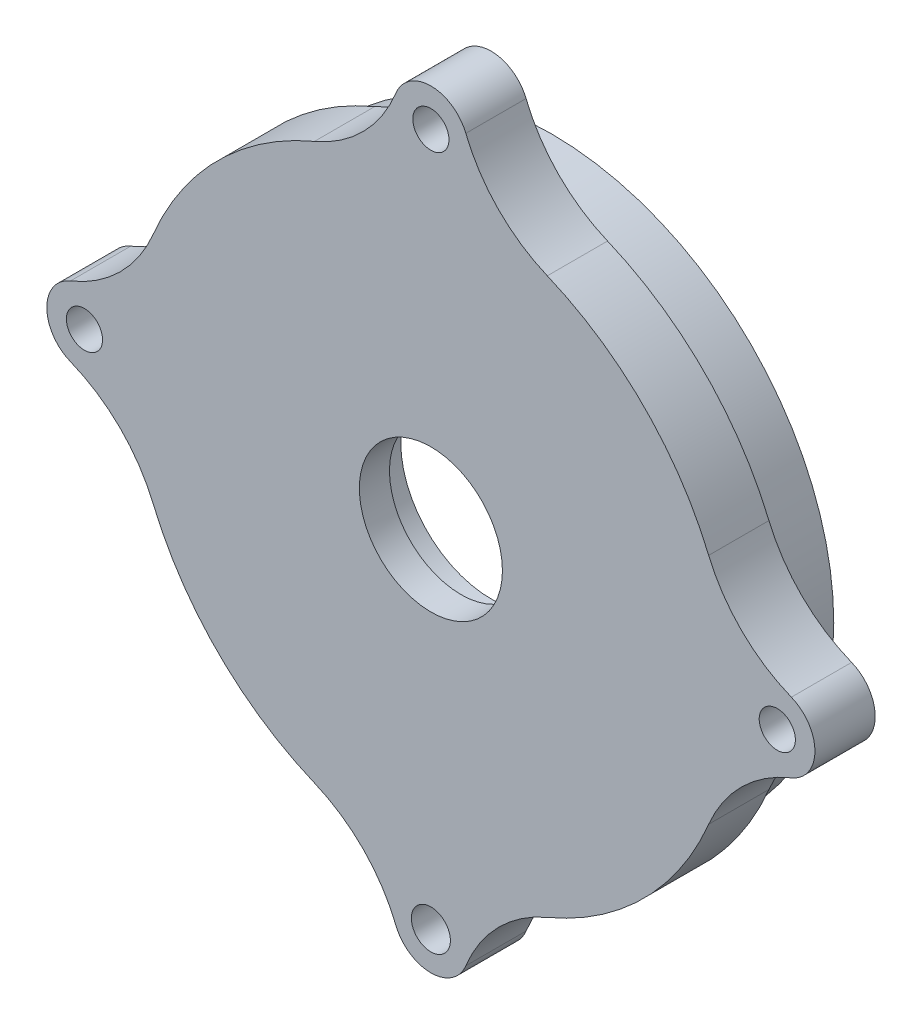
from build123d import *

# Parameters (mm, degrees)
SKETCH_1_R          = 20
EXTRUDE_1_DEPTH     = 4
SKETCH_2_R          = 6
CUT_EXTRUDE_1_DEPTH = 2
SKETCH_3_R          = 4.75
CUT_EXTRUDE_2_DEPTH = 22
SKETCH_4_R          = 18.75
SKETCH_4_R_2        = 17.5
EXTRUDE_2_DEPTH     = 4
SKETCH_5_R          = 1.294929457
SKETCH_5_R_2        = 1.2
EXTRUDE_3_DEPTH     = 4


with BuildPart() as part:
    # 草图1 → 凸台-拉伸1 (new body)
    with BuildSketch(Plane.XY):
        Circle(SKETCH_1_R)
    extrude(amount=EXTRUDE_1_DEPTH)

    # 草图2 → 切除-拉伸1 (cut)
    with BuildSketch(Plane(origin=(0, 0, 0), x_dir=(-1, 0, 0), z_dir=(0, 0, -1))):
        Circle(SKETCH_2_R)
    extrude(amount=-CUT_EXTRUDE_1_DEPTH, mode=Mode.SUBTRACT)

    # 草图3 → 切除-拉伸2 (cut)
    with BuildSketch(Plane.XY.offset(4)):
        Circle(SKETCH_3_R)
    extrude(amount=-CUT_EXTRUDE_2_DEPTH, mode=Mode.SUBTRACT)

    # 草图4 → 凸台-拉伸2 (add)
    with BuildSketch(Plane(origin=(0, 0, 0), x_dir=(-1, 0, 0), z_dir=(0, 0, -1))):
        Circle(SKETCH_4_R)
        Circle(SKETCH_4_R_2, mode=Mode.SUBTRACT)
    extrude(amount=EXTRUDE_2_DEPTH)

    # 草图5 → 凸台-拉伸3 (add)
    with BuildSketch(Plane.XY.offset(4)):
        with BuildLine():
            ThreePointArc((-2.319097331, -23.933695652), (0, -25.5), (2.319097331, -23.933695652))
            ThreePointArc((2.319097331, -23.933695652), (4.474759898, -20.647420615), (7.730324436, -18.445652174))
            ThreePointArc((7.730324436, -18.445652174), (0, -20), (-7.730324436, -18.445652174))
            ThreePointArc((-7.730324436, -18.445652174), (-4.474759898, -20.647420615), (-2.319097331, -23.933695652))
        make_face()
        with Locations((0, -23)):
            Circle(SKETCH_5_R, mode=Mode.SUBTRACT)
        with BuildLine():
            ThreePointArc((-23.933695652, 2.319097331), (-25.5, 0), (-23.933695652, -2.319097331))
            ThreePointArc((-23.933695652, -2.319097331), (-20.647420615, -4.474759898), (-18.445652174, -7.730324436))
            ThreePointArc((-18.445652174, -7.730324436), (-20, 0), (-18.445652174, 7.730324436))
            ThreePointArc((-18.445652174, 7.730324436), (-20.647420615, 4.474759898), (-23.933695652, 2.319097331))
        make_face()
        with Locations((-23, 0)):
            Circle(SKETCH_5_R_2, mode=Mode.SUBTRACT)
        with BuildLine():
            ThreePointArc((23.933695652, -2.319097331), (25.5, 0), (23.933695652, 2.319097331))
            ThreePointArc((23.933695652, 2.319097331), (20.647420615, 4.474759898), (18.445652174, 7.730324436))
            ThreePointArc((18.445652174, 7.730324436), (20, 0), (18.445652174, -7.730324436))
            ThreePointArc((18.445652174, -7.730324436), (20.647420615, -4.474759898), (23.933695652, -2.319097331))
        make_face()
        with Locations((23, 0)):
            Circle(SKETCH_5_R_2, mode=Mode.SUBTRACT)
        with BuildLine():
            ThreePointArc((2.319097331, 23.933695652), (0, 25.5), (-2.319097331, 23.933695652))
            ThreePointArc((-2.319097331, 23.933695652), (-4.474759898, 20.647420615), (-7.730324436, 18.445652174))
            ThreePointArc((-7.730324436, 18.445652174), (0, 20), (7.730324436, 18.445652174))
            ThreePointArc((7.730324436, 18.445652174), (4.474759898, 20.647420615), (2.319097331, 23.933695652))
        make_face()
        with Locations((0, 23)):
            Circle(SKETCH_5_R_2, mode=Mode.SUBTRACT)
    extrude(amount=-EXTRUDE_3_DEPTH)


solid = part.part
